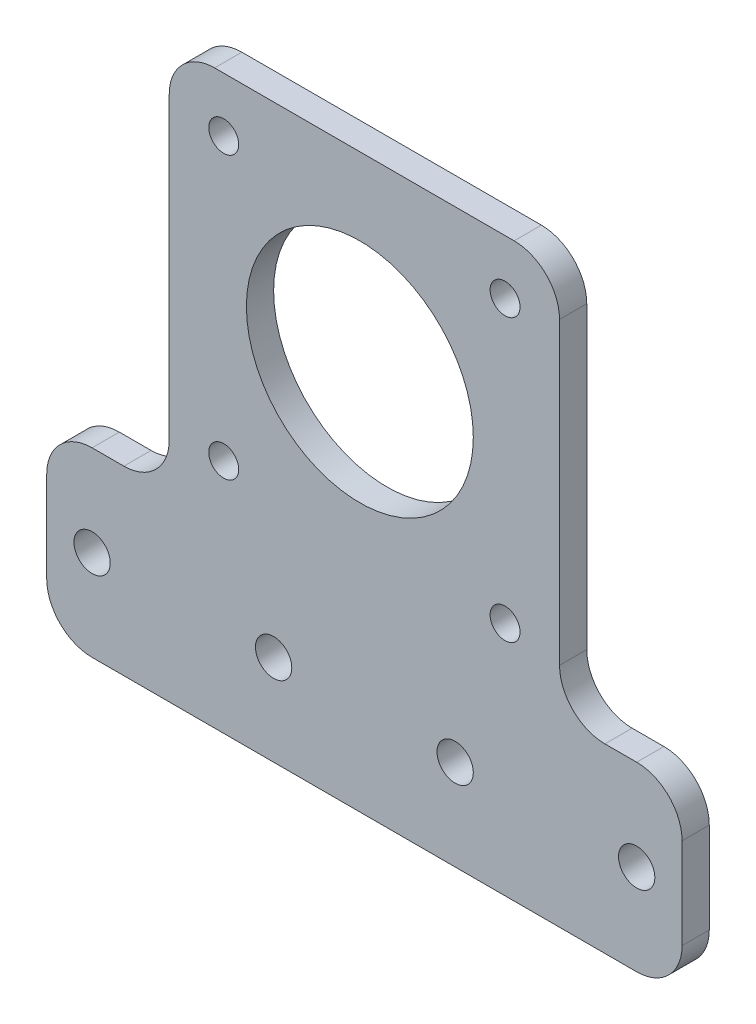
from build123d import *

# Parameters (mm, degrees)
SKETCH1_W           = 43
SKETCH1_H           = 43
SKETCH1_R           = 1.65
SKETCH1_W_2         = 70
SKETCH1_H_2         = 20
BOSS_EXTRUDE1_DEPTH = 3
FILLET1_R           = 5
SKETCH2_R           = 2
CUT_EXTRUDE1_DEPTH  = 3
SKETCH3_R           = 12.5
CUT_EXTRUDE2_DEPTH  = 3


with BuildPart() as part:
    # Sketch1 → Boss-Extrude1 (new body)
    with BuildSketch(Plane.XY):
        with Locations((35, 41.5)):
            Rectangle(SKETCH1_W, SKETCH1_H)
        with Locations((19.5, 26)):
            Circle(SKETCH1_R, mode=Mode.SUBTRACT)
        with Locations((50.5, 26)):
            Circle(SKETCH1_R, mode=Mode.SUBTRACT)
        with Locations((19.5, 57)):
            Circle(SKETCH1_R, mode=Mode.SUBTRACT)
        with Locations((50.5, 57)):
            Circle(SKETCH1_R, mode=Mode.SUBTRACT)
        with Locations((35, 10)):
            Rectangle(SKETCH1_W_2, SKETCH1_H_2)
    extrude(amount=BOSS_EXTRUDE1_DEPTH)

    # Fillet1
    fillet1_edges = [part.edges().sort_by_distance(p)[0] for p in [
        (56.5, 20, 1.5),
        (70, 20, 1.5),
        (70, 0, 1.5),
        (0, 0, 1.5),
        (0, 20, 1.5),
        (13.5, 20, 1.5),
        (13.5, 63, 1.5),
        (56.5, 63, 1.5),
    ]]
    fillet(fillet1_edges, radius=FILLET1_R)

    # Sketch2 → Cut-Extrude1 (cut)
    with BuildSketch(Plane.XY.offset(3)):
        with Locations((5, 10)):
            Circle(SKETCH2_R)
        with Locations((25, 10)):
            Circle(SKETCH2_R)
        with Locations((45, 10)):
            Circle(SKETCH2_R)
        with Locations((65, 10)):
            Circle(SKETCH2_R)
    extrude(amount=-CUT_EXTRUDE1_DEPTH, mode=Mode.SUBTRACT)

    # Sketch3 → Cut-Extrude2 (cut)
    with BuildSketch(Plane.XY.offset(3)):
        with Locations((34.5, 42)):
            Circle(SKETCH3_R)
    extrude(amount=-CUT_EXTRUDE2_DEPTH, mode=Mode.SUBTRACT)


solid = part.part
